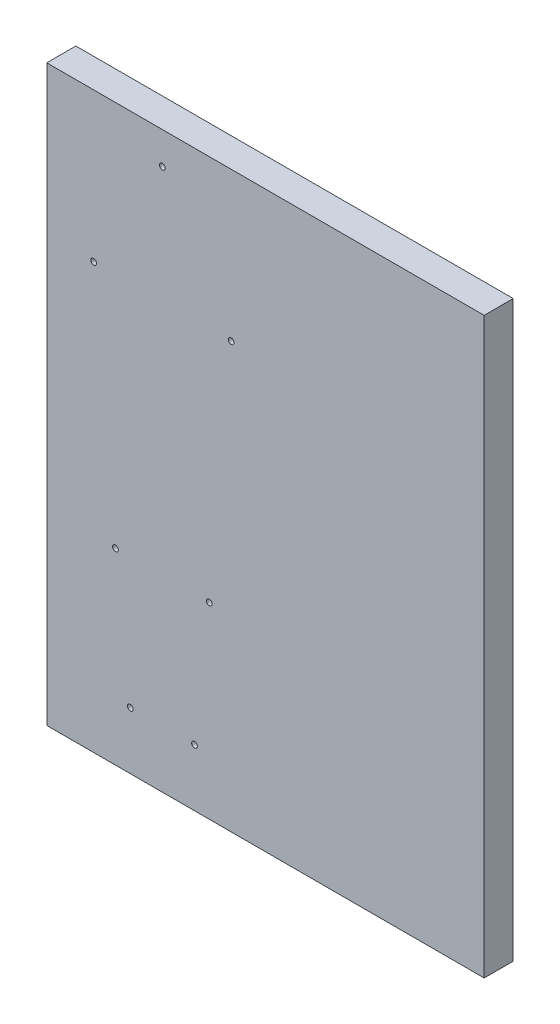
from build123d import *

# Parameters (mm, degrees)
SKETCH1_W             = 191
SKETCH1_H             = 250.6
BOSS_EXTRUDE1_DEPTH   = 12.7
M3X0_5_TAPPED_HOLE1_D = 2.5


with BuildPart() as part:
    # Sketch1 → Boss-Extrude1 (new body)
    with BuildSketch(Plane.XY):
        with Locations((70, -55.3)):
            Rectangle(SKETCH1_W, SKETCH1_H)
    extrude(amount=BOSS_EXTRUDE1_DEPTH)

    # M3x0.5 Tapped Hole1 (through all)
    with Locations(Plane(origin=(0, 0, 0), x_dir=(-1, 0, 0), z_dir=(0, 0, -1))):
        with Locations((-25, 56), (-55, 5), (5, 5), (-45.5, -98.6), (-4.5, -98.6), (-11, -155.6), (-39, -155.6)):
            Hole(M3X0_5_TAPPED_HOLE1_D / 2)


solid = part.part
